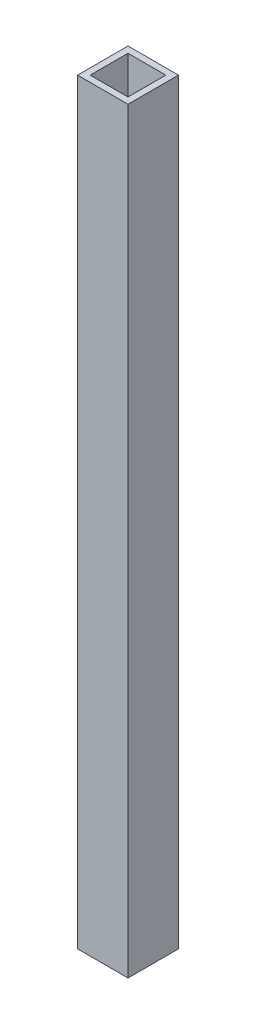
from build123d import *

# Parameters (mm, degrees)
SKETCH1_W           = 12.7
SKETCH1_H           = 12.7
SKETCH1_W_2         = 9.525
SKETCH1_H_2         = 9.525
BOSS_EXTRUDE1_DEPTH = 190.5


with BuildPart() as part:
    # Sketch1 → Boss-Extrude1 (new body)
    with BuildSketch(Plane(origin=(0, 0, 0), x_dir=(1, 0, 0), z_dir=(0, 1, 0))):
        with Locations((6.35, 6.35)):
            Rectangle(SKETCH1_W, SKETCH1_H)
        with Locations((6.35, 6.35)):
            Rectangle(SKETCH1_W_2, SKETCH1_H_2, mode=Mode.SUBTRACT)
    extrude(amount=BOSS_EXTRUDE1_DEPTH)


solid = part.part
